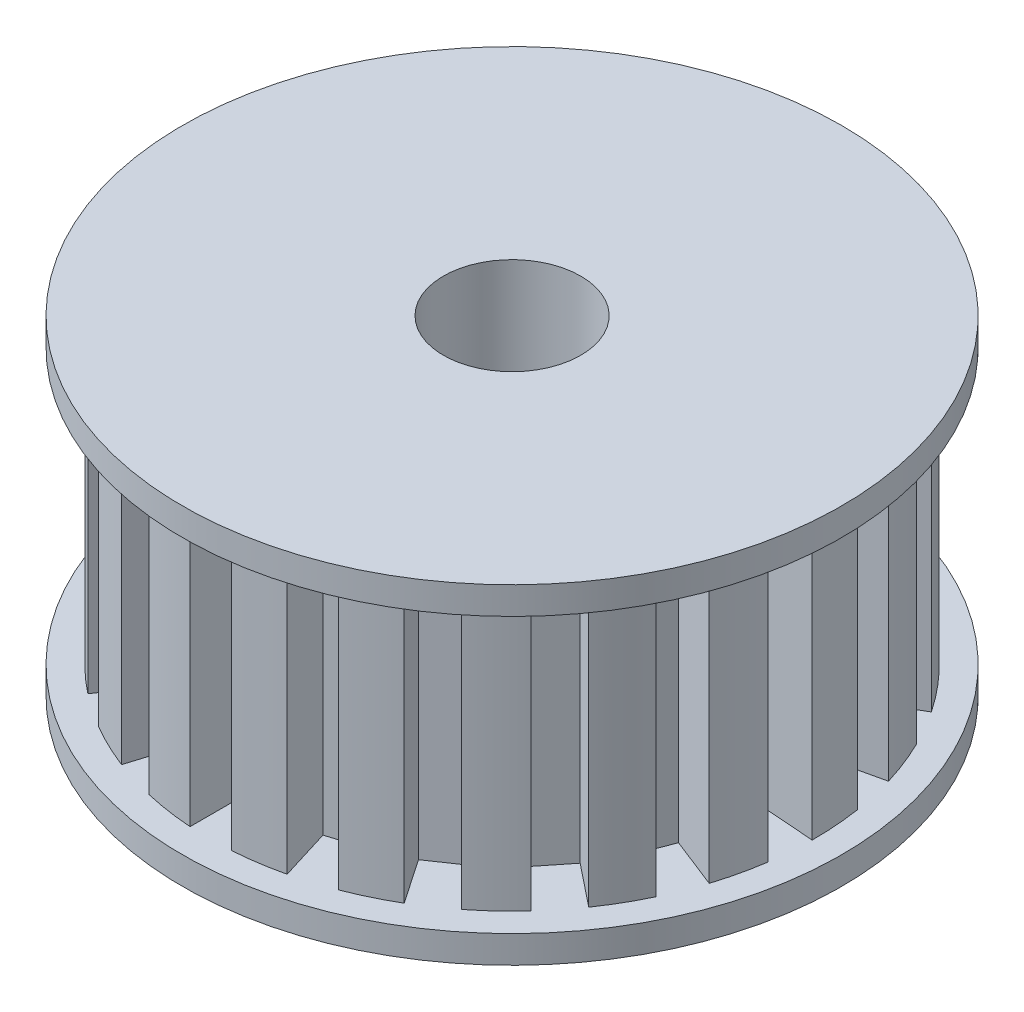
from build123d import *

# Parameters (mm, degrees)
SKETCH2_W          = 1.5
SKETCH2_H          = 10
CUT_EXTRUDE1_DEPTH = 2
CIRPATTERN1_COUNT  = 21


with BuildPart() as part:
    # Sketch1 → Revolve1 (revolve)
    with BuildSketch(Plane.XY, mode=Mode.PRIVATE) as revolve1_sk:
        Polygon((2.5, -5.930921053), (4.177631579, -5.930921053), (12, -5.930921053), (12, -4.930921053), (11, -4.930921053), (11, 5.069078947), (12, 5.069078947), (12, 6.069078947), (4.177631579, 6.069078947), (2.5, 6.069078947), align=None)
    revolve(revolve1_sk.sketch.rotate(Axis((0, 0, 0), (0, 1, 0)), 90), axis=Axis((0, 0, 0), (0, 1, 0)))  # turned: the seam where the file's is

    # Sketch2 → Cut-Extrude1 (cut)
    with BuildSketch(Plane.XY.offset(11)):
        with Locations((0, 0.069078947)):
            Rectangle(SKETCH2_W, SKETCH2_H)
    cut_extrude1 = extrude(amount=-CUT_EXTRUDE1_DEPTH, mode=Mode.SUBTRACT)

    # CirPattern1: Cut-Extrude1 ×21 about axis
    cirpattern1_axis = Axis((0, 0, 0), (0, 1, 0))
    for i in range(1, CIRPATTERN1_COUNT):
        add(cut_extrude1.rotate(cirpattern1_axis, i * 360 / CIRPATTERN1_COUNT), mode=Mode.SUBTRACT)


solid = part.part
